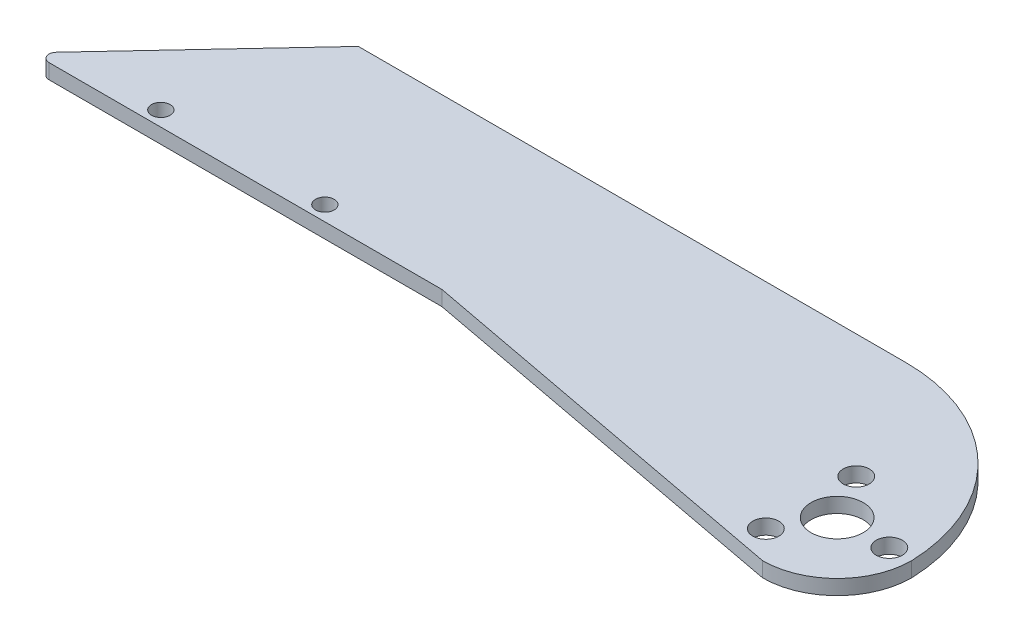
from build123d import *

# Parameters (mm, degrees)
SKETCH1_R           = 3.5
SKETCH1_R_2         = 1.25
SKETCH1_R_3         = 1.75
BOSS_EXTRUDE1_DEPTH = 2
FILLET_1_R          = 1


with BuildPart() as part:
    # Sketch1 → Boss-Extrude1 (new body)
    with BuildSketch(Plane(origin=(0, 0, 0), x_dir=(1, 0, 0), z_dir=(0, 1, 0))):
        with BuildLine():
            Line((-13.426718388, 22.622894631), (-86.83738777, 22.622894631))
            Line((-86.83738777, 22.622894631), (-108, 0))
            Line((-108, 0), (-53, 0))
            Line((-53, 0), (0, -10))
            ThreePointArc((0, -10), (7.071067812, -7.071067812), (10, 0))
            ThreePointArc((10, 0), (2.856758636, 16.043947959), (-13.426718388, 22.622894631))
        make_face()
        Circle(SKETCH1_R, mode=Mode.SUBTRACT)
        with Locations((-92.705183178, 2)):
            Circle(SKETCH1_R_2, mode=Mode.SUBTRACT)
        with Locations((-70.705183178, 2)):
            Circle(SKETCH1_R_2, mode=Mode.SUBTRACT)
        with Locations((-3.5, 6.062177826)):
            Circle(SKETCH1_R_3, mode=Mode.SUBTRACT)
        with Locations((7, 0)):
            Circle(SKETCH1_R_3, mode=Mode.SUBTRACT)
        with Locations((-3.5, -6.062177826)):
            Circle(SKETCH1_R_3, mode=Mode.SUBTRACT)
    extrude(amount=BOSS_EXTRUDE1_DEPTH)

    # Скругление1
    fillet_1_edges = [part.edges().sort_by_distance(p)[0] for p in [
        (-108, 1, 0),
    ]]
    fillet(fillet_1_edges, radius=FILLET_1_R)


solid = part.part
